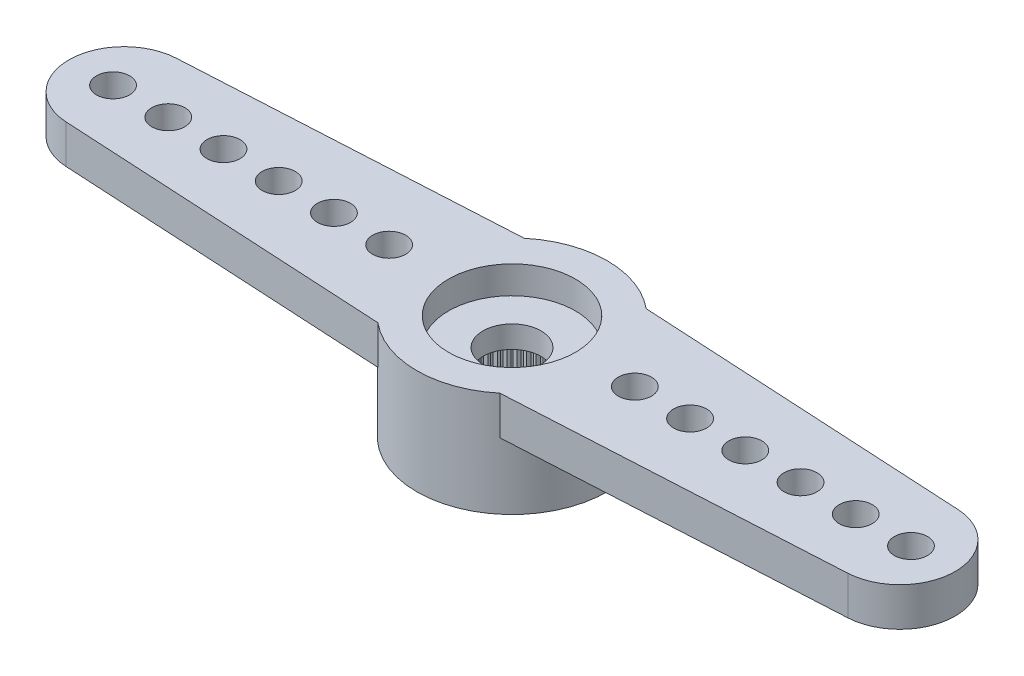
from build123d import *

# Parameters (mm, degrees)
RESSALTO_EXTRUS_O1_DEPTH = 1.4
ESBO_O2_R                = 3.45
RESSALTO_EXTRUS_O2_DEPTH = 2.4
FURO4_D                  = 1.2
PADR_O_LINEAR1_COUNT     = 6
PADR_O_LINEAR1_PITCH     = 2
PADR_OCIRCULAR2_COUNT    = 2
PADR_OCIRCULAR2_COPY_1_D = 1.2
PADR_OCIRCULAR2_COPY_2_D = 1.2
PADR_OCIRCULAR2_COPY_3_D = 1.2
PADR_OCIRCULAR2_COPY_4_D = 1.2
PADR_OCIRCULAR2_COPY_5_D = 1.2
FURO1_D                  = 4.95
FURO1_DEPTH              = 2
FURO2_D                  = 4.6
FURO2_DEPTH              = 1
FURO3_D                  = 2.1
RESSALTO_EXTRUS_O3_DEPTH = 2
PADR_OCIRCULAR1_COUNT    = 60


with BuildPart() as part:
    # Esboço1 → Ressalto-extrusão1 (new body)
    with BuildSketch(Plane(origin=(0, 0, 0), x_dir=(1, 0, 0), z_dir=(0, 1, 0))):
        with BuildLine():
            Line((-14.159121967, 1.99702088), (-2.209072203, 2.65))
            ThreePointArc((-2.209072203, 2.65), (3.45, 0), (-2.209072203, -2.65))
            Line((-2.209072203, -2.65), (-14.159121967, -1.99702088))
            ThreePointArc((-14.159121967, -1.99702088), (-16.05, 0), (-14.159121967, 1.99702088))
        make_face()
    ressalto_extrus_o1 = extrude(amount=-RESSALTO_EXTRUS_O1_DEPTH)

    # Esboço2 → Ressalto-extrusão2 (add)
    with BuildSketch(Plane.XZ.offset(1.4)):
        Circle(ESBO_O2_R)
    extrude(amount=RESSALTO_EXTRUS_O2_DEPTH)

    # Furo4 (through all)
    with Locations(Plane(origin=(0, 0, 0), x_dir=(1, 0, 0), z_dir=(0, 1, 0))):
        with Locations((-14.45, 0)):
            furo4 = Hole(FURO4_D / 2)

    # Padrão linear1: Furo4 ×6
    with Locations(*[(i * PADR_O_LINEAR1_PITCH, 0, 0) for i in range(1, PADR_O_LINEAR1_COUNT)]):
        add(furo4, mode=Mode.SUBTRACT)

    # PadrãoCircular2: Ressalto-extrusão1, Furo4 ×2 about axis
    padr_ocircular2_axis = Axis((0, 0, 0), (0, 1, 0))
    for i in range(1, PADR_OCIRCULAR2_COUNT):
        add(ressalto_extrus_o1.rotate(padr_ocircular2_axis, i * 360 / PADR_OCIRCULAR2_COUNT))
        add(furo4.rotate(padr_ocircular2_axis, i * 360 / PADR_OCIRCULAR2_COUNT), mode=Mode.SUBTRACT)

    # PadrãoCircular2 copy 1 (through all)
    with Locations(Plane(origin=(-2, 0, 0), x_dir=(-1, 0, 0), z_dir=(0, 1, 0))):
        with Locations((-14.45, 0)):
            Hole(PADR_OCIRCULAR2_COPY_1_D / 2)

    # PadrãoCircular2 copy 2 (through all)
    with Locations(Plane(origin=(-4, 0, 0), x_dir=(-1, 0, 0), z_dir=(0, 1, 0))):
        with Locations((-14.45, 0)):
            Hole(PADR_OCIRCULAR2_COPY_2_D / 2)

    # PadrãoCircular2 copy 3 (through all)
    with Locations(Plane(origin=(-6, 0, 0), x_dir=(-1, 0, 0), z_dir=(0, 1, 0))):
        with Locations((-14.45, 0)):
            Hole(PADR_OCIRCULAR2_COPY_3_D / 2)

    # PadrãoCircular2 copy 4 (through all)
    with Locations(Plane(origin=(-8, 0, 0), x_dir=(-1, 0, 0), z_dir=(0, 1, 0))):
        with Locations((-14.45, 0)):
            Hole(PADR_OCIRCULAR2_COPY_4_D / 2)

    # PadrãoCircular2 copy 5 (through all)
    with Locations(Plane(origin=(-10, 0, 0), x_dir=(-1, 0, 0), z_dir=(0, 1, 0))):
        with Locations((-14.45, 0)):
            Hole(PADR_OCIRCULAR2_COPY_5_D / 2)

    # Furo1
    with Locations(Plane(origin=(0, -3.8, 0), x_dir=(-1, 0, 0), z_dir=(0, -1, 0))):
        with Locations((0, 0)):
            Hole(FURO1_D / 2, depth=FURO1_DEPTH)

    # Furo2
    with Locations(Plane(origin=(0, 0, 0), x_dir=(1, 0, 0), z_dir=(0, 1, 0))):
        with Locations((0, 0)):
            Hole(FURO2_D / 2, depth=FURO2_DEPTH)

    # Furo3 (through all)
    with Locations(Plane(origin=(0, 0, 0), x_dir=(1, 0, 0), z_dir=(0, 1, 0))):
        with Locations((0, 0)):
            Hole(FURO3_D / 2)

    # Esboço11 → Ressalto-extrusão3 (add)
    with BuildSketch(Plane.XZ.offset(3.8)):
        with BuildLine():
            Line((-0.098056786, 2.473056786), (0, 2.375))
            Line((0, 2.375), (0.098056786, 2.473056786))
            ThreePointArc((0.098056786, 2.473056786), (0, 2.475), (-0.098056786, 2.473056786))
        make_face()
    ressalto_extrus_o3 = extrude(amount=-RESSALTO_EXTRUS_O3_DEPTH)

    # PadrãoCircular1: Ressalto-extrusão3 ×60 about axis
    padr_ocircular1_axis = Axis((0, 0, 0), (0, 1, 0))
    for i in range(1, PADR_OCIRCULAR1_COUNT):
        add(ressalto_extrus_o3.rotate(padr_ocircular1_axis, i * 360 / PADR_OCIRCULAR1_COUNT))


solid = part.part
